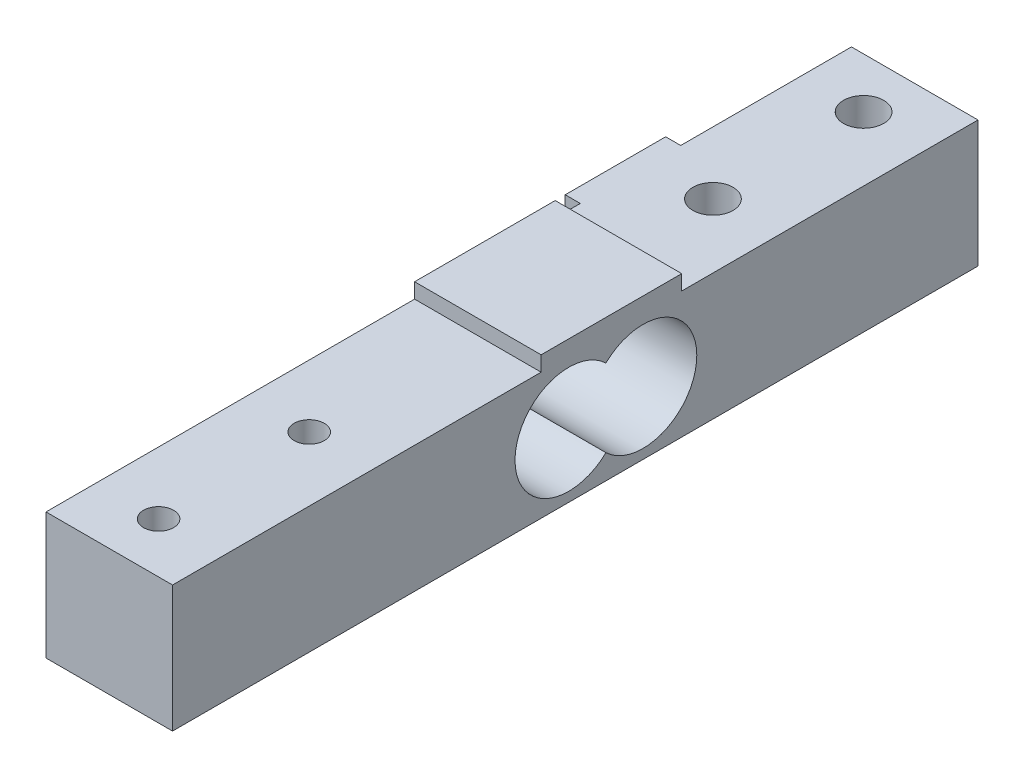
from build123d import *

# Parameters (mm, degrees)
ESQUISSE1_W             = 12.6
ESQUISSE1_H             = 12.6
BOSS_EXTRU_1_DEPTH      = 80.2
ESQUISSE2_R             = 1.5
ESQUISSE2_R_2           = 2
ENL_V_MAT_EXTRU_1_DEPTH = 13.6
ESQUISSE3_R             = 5.35
ENL_V_MAT_EXTRU_4_DEPTH = 13.6
ESQUISSE4_W             = 12.6
ESQUISSE4_H             = 14
BOSS_EXTRU_2_DEPTH      = 1.5
ESQUISSE5_W             = 10
ESQUISSE5_H             = 12.6
BOSS_EXTRU_3_DEPTH      = 1.5


with BuildPart() as part:
    # Esquisse1 → Boss.-Extru.1 (new body)
    with BuildSketch(Plane.XY):
        with Locations((6.3, 6.3)):
            Rectangle(ESQUISSE1_W, ESQUISSE1_H)
    extrude(amount=BOSS_EXTRU_1_DEPTH)

    # Esquisse2 → Enlèv. mat.-Extru.1 (cut, through all)
    with BuildSketch(Plane(origin=(0, 12.6, 0), x_dir=(1, 0, 0), z_dir=(0, 1, 0))):
        with Locations((6.208458314, -75.2)):
            Circle(ESQUISSE2_R)
        with Locations((6.208458314, -60.2)):
            Circle(ESQUISSE2_R)
        with Locations((6.208458314, -20)):
            Circle(ESQUISSE2_R_2)
        with Locations((6.208458314, -5)):
            Circle(ESQUISSE2_R_2)
    extrude(amount=-ENL_V_MAT_EXTRU_1_DEPTH, mode=Mode.SUBTRACT)

    # Esquisse3 → Enlèv. mat.-Extru.4 (cut, through all)
    with BuildSketch(Plane(origin=(12.6, 0, 0), x_dir=(0, 0, -1), z_dir=(1, 0, 0))):
        with Locations((-33.35, 6.3)):
            Circle(ESQUISSE3_R)
        with Locations((-40.75, 6.3)):
            Circle(ESQUISSE3_R)
    extrude(amount=-ENL_V_MAT_EXTRU_4_DEPTH, mode=Mode.SUBTRACT)

    # Esquisse4 → Boss.-Extru.2 (add)
    with BuildSketch(Plane(origin=(0, 12.6, 0), x_dir=(1, 0, 0), z_dir=(0, 1, 0))):
        with Locations((6.3, -36.5)):
            Rectangle(ESQUISSE4_W, ESQUISSE4_H)
    extrude(amount=BOSS_EXTRU_2_DEPTH)

    # Esquisse5 → Boss.-Extru.3 (add)
    with BuildSketch(Plane.ZY):
        with Locations((22, 6.3)):
            Rectangle(ESQUISSE5_W, ESQUISSE5_H)
    extrude(amount=BOSS_EXTRU_3_DEPTH)


solid = part.part
